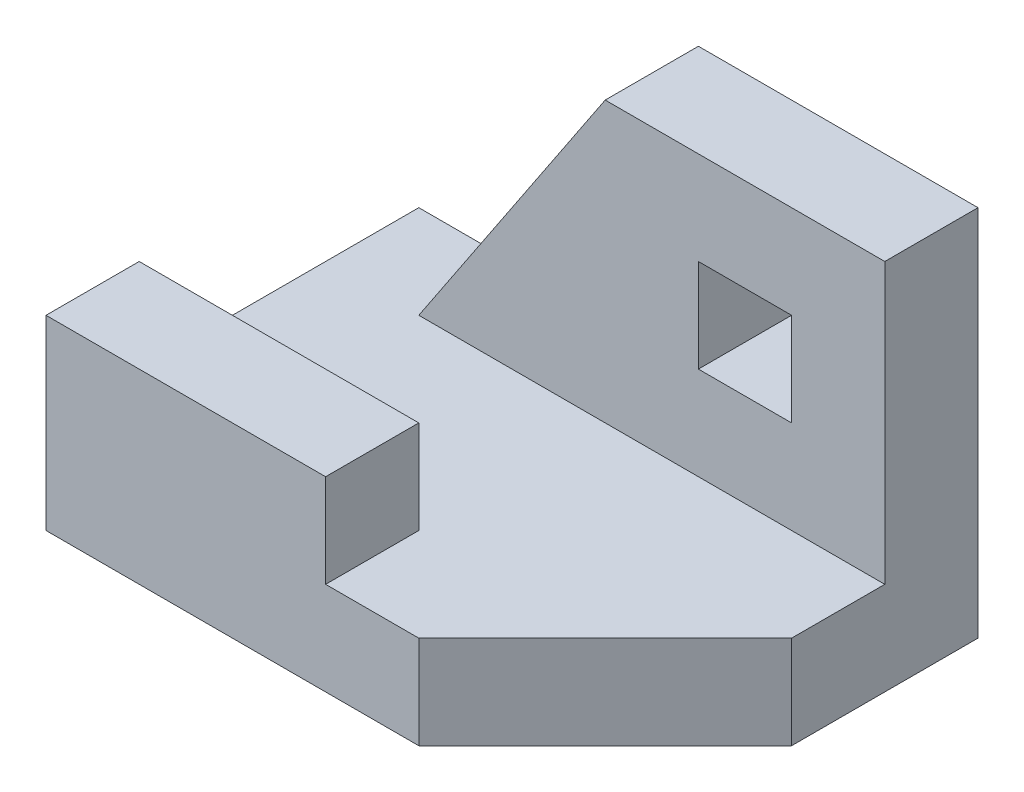
from build123d import *

# Parameters (mm, degrees)
EXTRUDE_1_DEPTH     = 1
SKETCH_1_3_W        = 3
SKETCH_1_3_H        = 1
EXTRUDE_2_DEPTH     = 2
SKETCH_1_4_W        = 5
SKETCH_1_4_H        = 1
EXTRUDE_3_DEPTH     = 4
SKETCH_2_W          = 1
SKETCH_2_H          = 1
CUT_EXTRUDE_1_DEPTH = 4


with BuildPart() as part:
    # 草圖1 → 填料-伸長1 (new body)
    with BuildSketch(Plane(origin=(0, 0, 0), x_dir=(1, 0, 0), z_dir=(0, 1, 0))):
        Polygon((4, 0), (6, 2), (6, 4), (0, 4), (0, 0), align=None)
    extrude(amount=EXTRUDE_1_DEPTH)

    # 草圖1<3> → 填料-伸長2 (add)
    with BuildSketch(Plane(origin=(0, 0, 0), x_dir=(1, 0, 0), z_dir=(0, 1, 0))):
        with Locations((1.5, 0.5)):
            Rectangle(SKETCH_1_3_W, SKETCH_1_3_H)
    extrude(amount=EXTRUDE_2_DEPTH)

    # 草圖1<4> → 填料-伸長3 (add)
    with BuildSketch(Plane(origin=(0, 0, 0), x_dir=(1, 0, 0), z_dir=(0, 1, 0))):
        with Locations((3.5, 3.5)):
            Rectangle(SKETCH_1_4_W, SKETCH_1_4_H)
    extrude(amount=EXTRUDE_3_DEPTH)

    # 草圖2 → 除料-伸長1 (cut)
    with BuildSketch(Plane.XY.offset(-3)):
        with Locations((4.5, 2.5)):
            Rectangle(SKETCH_2_W, SKETCH_2_H)
        Polygon((1, 4), (3, 4), (1, 1), align=None)
    extrude(amount=-CUT_EXTRUDE_1_DEPTH, mode=Mode.SUBTRACT)


solid = part.part
